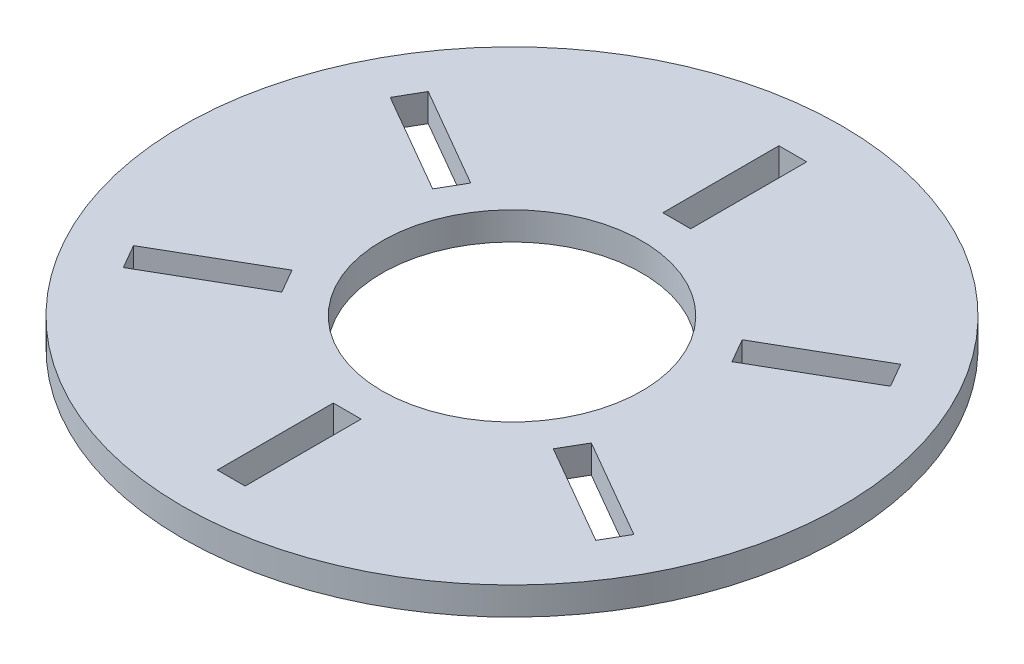
from build123d import *

# Parameters (mm, degrees)
ESQUISSE1_R             = 71
ESQUISSE1_R_2           = 28
BOSS_EXTRU_1_DEPTH      = 6
ESQUISSE2_W             = 6
ESQUISSE2_H             = 25
ENL_V_MAT_EXTRU_1_DEPTH = 10


with BuildPart() as part:
    # Esquisse1 → Boss.-Extru.1 (new body)
    with BuildSketch(Plane(origin=(0, 0, 0), x_dir=(1, 0, 0), z_dir=(0, 1, 0))):
        Circle(ESQUISSE1_R)
        Circle(ESQUISSE1_R_2, mode=Mode.SUBTRACT)
    extrude(amount=BOSS_EXTRU_1_DEPTH)

    # Esquisse2 → Enlèv. mat.-Extru.1 (cut)
    with BuildSketch(Plane.XZ):
        Polygon((50.894536929, -32.848076211), (29.243901834, -20.348076211), (32.243901834, -15.151923789), (53.894536929, -27.651923789), align=None)
        with Locations((0, -48)):
            Rectangle(ESQUISSE2_W, ESQUISSE2_H)
        Polygon((53.894536929, 27.651923789), (32.243901834, 15.151923789), (29.243901834, 20.348076211), (50.894536929, 32.848076211), align=None)
        with Locations((0, 48)):
            Rectangle(ESQUISSE2_W, ESQUISSE2_H)
        Polygon((-50.894536929, 32.848076211), (-29.243901834, 20.348076211), (-32.243901834, 15.151923789), (-53.894536929, 27.651923789), align=None)
        Polygon((-53.894536929, -27.651923789), (-32.243901834, -15.151923789), (-29.243901834, -20.348076211), (-50.894536929, -32.848076211), align=None)
    extrude(amount=-ENL_V_MAT_EXTRU_1_DEPTH, mode=Mode.SUBTRACT)


solid = part.part
